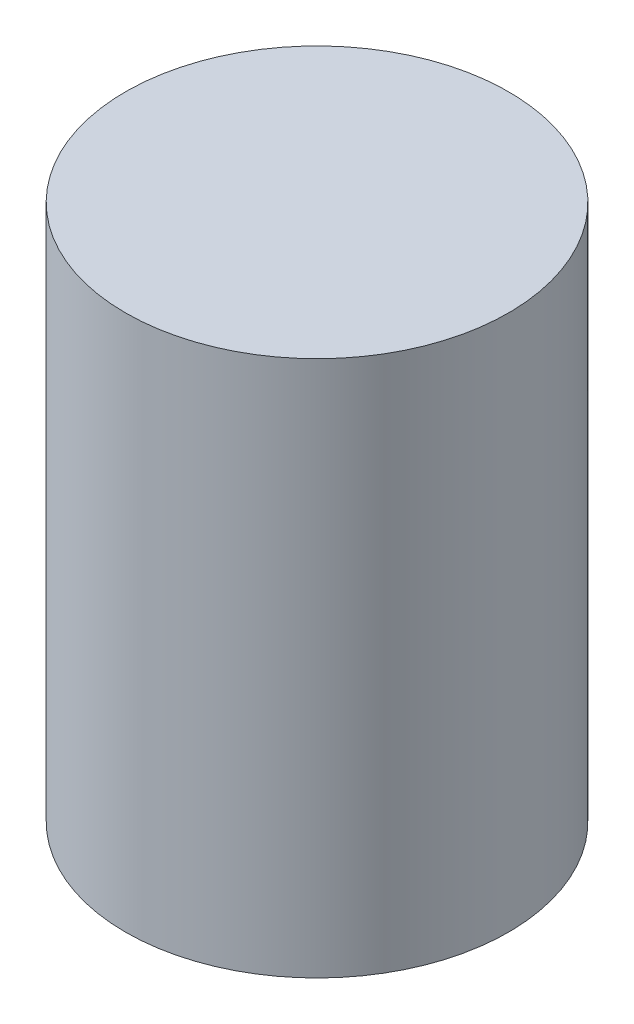
from build123d import *


with BuildPart() as part:
    # Sketch1 → Revolve1 (revolve)
    with BuildSketch(Plane(origin=(0, 0, 0), x_dir=(0, 0, -1), z_dir=(1, 0, 0))):
        Polygon((0, 582.834408602), (381, 582.834408602), (381, -483.965591398), (0, -483.965591398), (0, -477.615591398), (374.65, -477.615591398), (374.65, 576.484408602), (0, 576.484408602), align=None)
    revolve(axis=Axis((0, 582.834408602, 0), (0, -1, 0)))


solid = part.part
